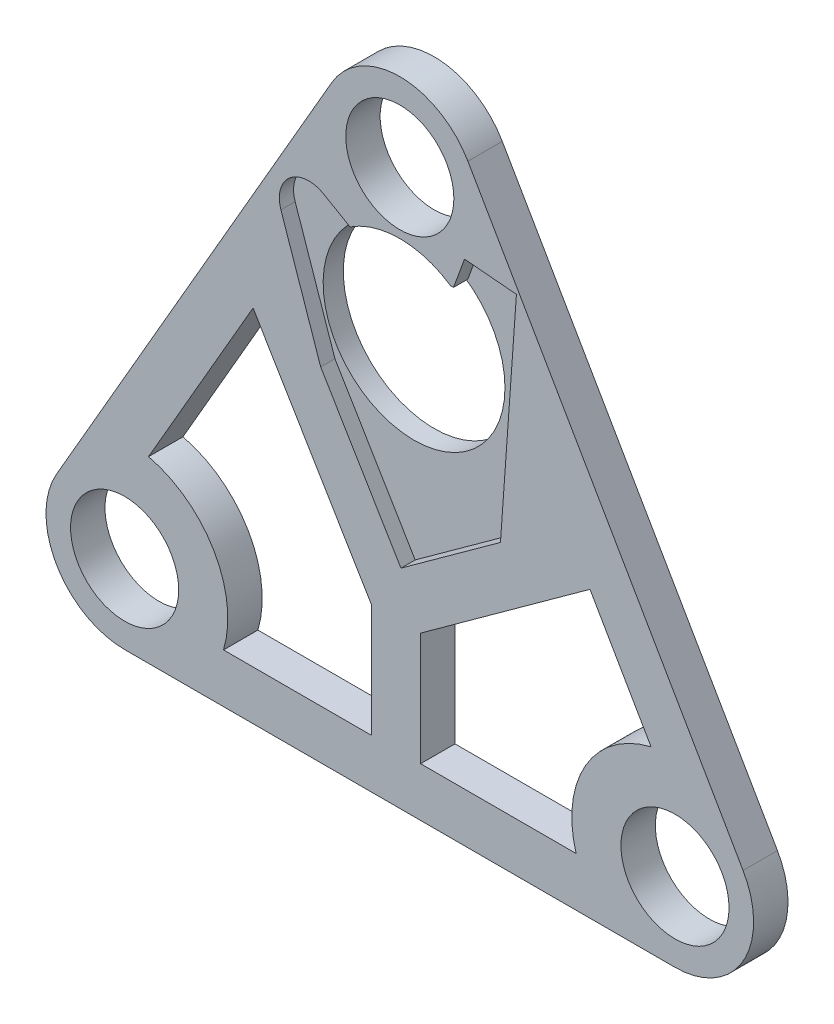
from build123d import *

# Parameters (mm, degrees)
SKETCH1_R           = 11
BOSS_EXTRUDE1_DEPTH = 7
SKETCH3_R           = 18.5
CUT_EXTRUDE1_DEPTH  = 8
CUT_EXTRUDE2_DEPTH  = 2.9
CUT_EXTRUDE3_DEPTH  = 8


with BuildPart() as part:
    # Sketch1 → Boss-Extrude1 (new body)
    with BuildSketch(Plane.XY):
        with BuildLine():
            Line((42.143593539, 104.994845224), (-13.856406461, 8))
            ThreePointArc((-13.856406461, 8), (-13.856406461, -8), (0, -16))
            Line((0, -16), (112, -16))
            ThreePointArc((112, -16), (125.856406461, -8), (125.856406461, 8))
            Line((125.856406461, 8), (69.856406461, 104.994845224))
            ThreePointArc((69.856406461, 104.994845224), (56, 112.994845224), (42.143593539, 104.994845224))
        make_face()
        Circle(SKETCH1_R, mode=Mode.SUBTRACT)
        with Locations((112, 0)):
            Circle(SKETCH1_R, mode=Mode.SUBTRACT)
        with Locations((56, 96.994845224)):
            Circle(SKETCH1_R, mode=Mode.SUBTRACT)
    extrude(amount=BOSS_EXTRUDE1_DEPTH)

    # Sketch3 → Cut-Extrude1 (cut, through all)
    with BuildSketch(Plane.XY.offset(7)):
        with Locations((56, 65.944845224)):
            Circle(SKETCH3_R)
    extrude(amount=-CUT_EXTRUDE1_DEPTH, mode=Mode.SUBTRACT)

    # Sketch4 → Cut-Extrude2 (cut)
    with BuildSketch(Plane.XY.offset(7)):
        with BuildLine():
            Line((46.11, 81.294845224), (66.94, 81.294845224))
            Line((66.94, 81.294845224), (69.163130932, 87.402847259))
            Line((69.163130932, 87.402847259), (79.735172855, 86.47791344))
            Line((79.735172855, 86.47791344), (76.482447168, 41.124405576))
            Line((76.482447168, 41.124405576), (56.230844768, 26.465872217))
            Line((56.230844768, 26.465872217), (39.901277947, 53.752961607))
            Line((39.901277947, 53.752961607), (31.804248297, 77.405405685))
            ThreePointArc((31.804248297, 77.405405685), (33.66849594, 83.981842037), (40.480834875, 84.544845224))
            Line((40.480834875, 84.544845224), (46.11, 81.294845224))
        make_face()
    extrude(amount=-CUT_EXTRUDE2_DEPTH, mode=Mode.SUBTRACT)

    # Sketch5 → Cut-Extrude3 (cut, through all)
    with BuildSketch(Plane.XY.offset(7)):
        with BuildLine():
            Line((26.139616059, 57.275143104), (4.866153476, 20.428425058))
            ThreePointArc((4.866153476, 20.428425058), (18.186533479, 10.5), (20.124611797, -6))
            Line((20.124611797, -6), (50.231546624, -6))
            Line((50.231546624, -6), (50.231546624, 17.016961725))
            Line((50.231546624, 17.016961725), (26.139616059, 57.275143104))
        make_face()
        with BuildLine():
            Line((60.231546624, 17.016961725), (60.231546624, -6))
            Line((60.231546624, -6), (91.875388203, -6))
            ThreePointArc((91.875388203, -6), (93.813466521, 10.5), (107.133846524, 20.428425058))
            Line((107.133846524, 20.428425058), (94.699401361, 41.965515845))
            Line((94.699401361, 41.965515845), (60.231546624, 17.016961725))
        make_face()
    extrude(amount=-CUT_EXTRUDE3_DEPTH, mode=Mode.SUBTRACT)


solid = part.part
